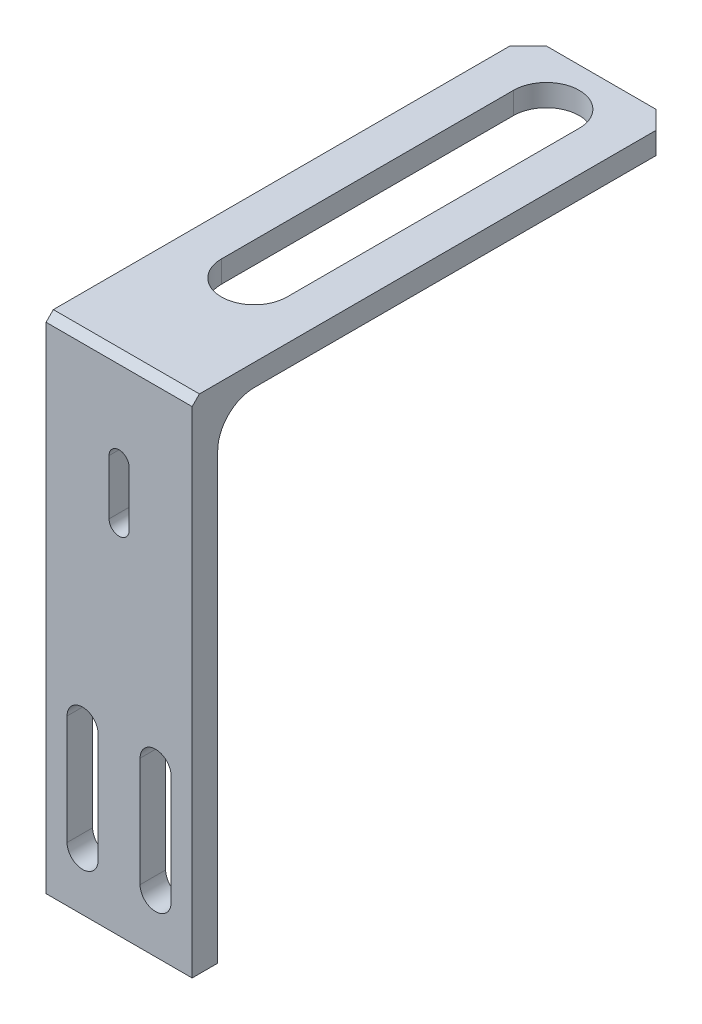
from build123d import *

# Parameters (mm, degrees)
SKETCH2_W           = 40
SKETCH2_H           = 137.5
BOSS_EXTRUDE1_DEPTH = 7
SKETCH4_W           = 40
SKETCH4_H           = 125
BOSS_EXTRUDE2_DEPTH = 6
FILLET1_R           = 10
CHAMFER1_SIZE       = 5
CHAMFER2_SIZE       = 2


with BuildPart() as part:
    # Sketch2 → Boss-Extrude1 (new body)
    with BuildSketch(Plane.XY):
        with Locations((0, 33.75)):
            Rectangle(SKETCH2_W, SKETCH2_H)
        with BuildLine():
            Line((-5.75, 10), (-5.75, -20))
            ThreePointArc((-5.75, -20), (-10, -24.25), (-14.25, -20))
            Line((-14.25, -20), (-14.25, 10))
            ThreePointArc((-14.25, 10), (-10, 14.25), (-5.75, 10))
        make_face(mode=Mode.SUBTRACT)
        with BuildLine():
            Line((5.75, 10), (5.75, -20))
            ThreePointArc((5.75, -20), (10, -24.25), (14.25, -20))
            Line((14.25, -20), (14.25, 10))
            ThreePointArc((14.25, 10), (10, 14.25), (5.75, 10))
        make_face(mode=Mode.SUBTRACT)
        with BuildLine():
            Line((2.75, 77.5), (2.75, 62.5))
            ThreePointArc((2.75, 62.5), (0, 59.75), (-2.75, 62.5))
            Line((-2.75, 62.5), (-2.75, 77.5))
            ThreePointArc((-2.75, 77.5), (0, 80.25), (2.75, 77.5))
        make_face(mode=Mode.SUBTRACT)
    extrude(amount=BOSS_EXTRUDE1_DEPTH)

    # Sketch4 → Boss-Extrude2 (add)
    with BuildSketch(Plane(origin=(0, 102.5, 0), x_dir=(1, 0, 0), z_dir=(0, 1, 0))):
        with Locations((0, 62.5)):
            Rectangle(SKETCH4_W, SKETCH4_H)
        with BuildLine():
            Line((-9, 30), (-9, 110))
            ThreePointArc((-9, 110), (0, 119), (9, 110))
            Line((9, 110), (9, 30))
            ThreePointArc((9, 30), (0, 21), (-9, 30))
        make_face(mode=Mode.SUBTRACT)
    extrude(amount=-BOSS_EXTRUDE2_DEPTH)

    # Fillet1
    fillet1_edges = [part.edges().sort_by_distance(p)[0] for p in [
        (0, 96.5, 0),
    ]]
    fillet(fillet1_edges, radius=FILLET1_R)

    # Chamfer1
    chamfer1_edges = [part.edges().sort_by_distance(p)[0] for p in [
        (-20, 99.5, -125),
        (20, 99.5, -125),
    ]]
    chamfer(chamfer1_edges, length=CHAMFER1_SIZE)

    # Chamfer2
    chamfer2_edges = [part.edges().sort_by_distance(p)[0] for p in [
        (0, 102.5, 7),
    ]]
    chamfer(chamfer2_edges, length=CHAMFER2_SIZE)


solid = part.part
